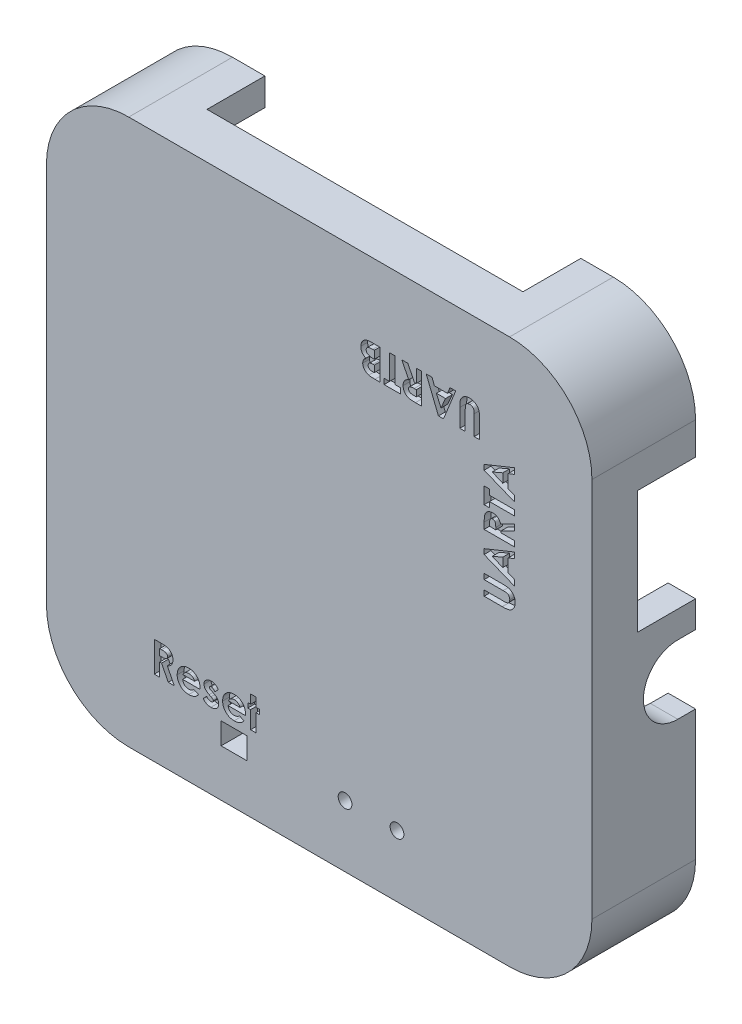
from build123d import *

# Parameters (mm, degrees)
BOSS_EXTRUDE1_DEPTH = 3.175
BOSS_EXTRUDE2_DEPTH = 8.8
CUT_EXTRUDE1_REACH  = 65.033
SKETCH3_W           = 6.6875
SKETCH3_H           = 14.175
SKETCH5_W           = 36.506
SKETCH5_H           = 6.6875
CUT_EXTRUDE2_DEPTH  = 3.175
SKETCH6_W           = 6.604
SKETCH6_H           = 12.954
CUT_EXTRUDE3_DEPTH  = 3.175
SKETCH7_R           = 0.79375
SKETCH7_W           = 3
SKETCH7_H           = 2.5
CUT_EXTRUDE4_DEPTH  = 3.175
CUT_EXTRUDE5_DEPTH  = 0.79375


with BuildPart() as part:
    # Sketch1 → Boss-Extrude1 (new body)
    with BuildSketch(Plane.XY):
        with BuildLine():
            Line((22, 31.5165), (-22, 31.5165))
            ThreePointArc((-22, 31.5165), (-28.729181683, 28.729181683), (-31.5165, 22))
            Line((-31.5165, 22), (-31.5165, -22))
            ThreePointArc((-31.5165, -22), (-28.729181683, -28.729181683), (-22, -31.5165))
            Line((-22, -31.5165), (22, -31.5165))
            ThreePointArc((22, -31.5165), (28.729181683, -28.729181683), (31.5165, -22))
            Line((31.5165, -22), (31.5165, 22))
            ThreePointArc((31.5165, 22), (28.729181683, 28.729181683), (22, 31.5165))
        make_face()
    extrude(amount=BOSS_EXTRUDE1_DEPTH)

    # Sketch1_3 → Boss-Extrude2 (add)
    with BuildSketch(Plane.XY):
        with BuildLine():
            Line((22, 31.5165), (-22, 31.5165))
            ThreePointArc((-22, 31.5165), (-28.729181683, 28.729181683), (-31.5165, 22))
            Line((-31.5165, 22), (-31.5165, -22))
            ThreePointArc((-31.5165, -22), (-28.729181683, -28.729181683), (-22, -31.5165))
            Line((-22, -31.5165), (22, -31.5165))
            ThreePointArc((22, -31.5165), (28.729181683, -28.729181683), (31.5165, -22))
            Line((31.5165, -22), (31.5165, 22))
            ThreePointArc((31.5165, 22), (28.729181683, 28.729181683), (22, 31.5165))
        make_face()
        with BuildLine():
            Line((-28.3415, 22), (-28.3415, -22))
            ThreePointArc((-28.3415, -22), (-26.484117653, -26.484117653), (-22, -28.3415))
            Line((-22, -28.3415), (22, -28.3415))
            ThreePointArc((22, -28.3415), (26.484117653, -26.484117653), (28.3415, -22))
            Line((28.3415, -22), (28.3415, 22))
            ThreePointArc((28.3415, 22), (26.484117653, 26.484117653), (22, 28.3415))
            Line((22, 28.3415), (-22, 28.3415))
            ThreePointArc((-22, 28.3415), (-26.484117653, 26.484117653), (-28.3415, 22))
        make_face(mode=Mode.SUBTRACT)
    extrude(amount=-BOSS_EXTRUDE2_DEPTH)

    # Sketch3 → Cut-Extrude1 (cut, up to next)
    with BuildSketch(Plane(origin=(31.5165, 0, 0), x_dir=(0, 0, -1), z_dir=(1, 0, 0)), mode=Mode.PRIVATE) as cut_extrude1_sk1:
        with BuildLine():
            Line((6.745, -6.94475), (8.8, -6.94475))
            Line((8.8, -6.94475), (8.8, -6.371283723))
            Line((8.8, -6.371283723), (8.8, 0.419283723))
            Line((8.8, 0.419283723), (8.8, 0.99275))
            Line((8.8, 0.99275), (6.745, 0.99275))
            ThreePointArc((6.745, 0.99275), (2.77625, -2.976), (6.745, -6.94475))
        make_face()
    cut_extrude1_tool1 = extrude(cut_extrude1_sk1.sketch, amount=-CUT_EXTRUDE1_REACH, mode=Mode.PRIVATE) & part.part
    add(cut_extrude1_tool1.solids().sort_by_distance((31.5165, -2.976, -6.13812))[0], mode=Mode.SUBTRACT)
    # Sketch3 → Cut-Extrude1 (cut, up to next)
    with BuildSketch(Plane(origin=(31.5165, 0, 0), x_dir=(0, 0, -1), z_dir=(1, 0, 0)), mode=Mode.PRIVATE) as cut_extrude1_sk2:
        with Locations((5.45625, 11.17)):
            Rectangle(SKETCH3_W, SKETCH3_H)
    cut_extrude1_tool2 = extrude(cut_extrude1_sk2.sketch, amount=-CUT_EXTRUDE1_REACH, mode=Mode.PRIVATE) & part.part
    add(cut_extrude1_tool2.solids().sort_by_distance((31.5165, 11.17, -5.45625))[0], mode=Mode.SUBTRACT)

    # Sketch5 → Cut-Extrude2 (cut)
    with BuildSketch(Plane(origin=(0, 31.5165, 0), x_dir=(1, 0, 0), z_dir=(0, 1, 0))):
        with Locations((0.0045, 5.45625)):
            Rectangle(SKETCH5_W, SKETCH5_H)
    extrude(amount=-CUT_EXTRUDE2_DEPTH, mode=Mode.SUBTRACT)

    # Sketch6 → Cut-Extrude3 (cut)
    with BuildSketch(Plane.ZY.offset(31.5165)):
        with Locations((-5.498, -8.73)):
            Rectangle(SKETCH6_W, SKETCH6_H)
    extrude(amount=-CUT_EXTRUDE3_DEPTH, mode=Mode.SUBTRACT)

    # Sketch7 → Cut-Extrude4 (cut)
    with BuildSketch(Plane.XY.offset(3.175)):
        with Locations((2.99, -24.39)):
            Circle(SKETCH7_R)
        with Locations((8.99, -24.39)):
            Circle(SKETCH7_R)
        with Locations((-9.83, -24.82)):
            Rectangle(SKETCH7_W, SKETCH7_H)
    extrude(amount=-CUT_EXTRUDE4_DEPTH, mode=Mode.SUBTRACT)

    # Sketch8 → Cut-Extrude5 (cut)
    with BuildSketch(Plane.XY.offset(3.175)):
        with BuildLine():
            Line((-19.05449378, -19.261955354), (-18.322522626, -19.261955354))
            add(Edge.make_bspline(
                [(-18.322522626, -19.261955354), (-18.274139555, -19.262127086), (-18.181085282, -19.262457375), (-18.046906103, -19.267668465), (-17.923644074, -19.274920124), (-17.811116694, -19.285986348), (-17.709372106, -19.300658824), (-17.618308337, -19.317955244), (-17.537928049, -19.337668224), (-17.467553345, -19.362232152), (-17.404043654, -19.38993989), (-17.344843793, -19.42177659), (-17.288647724, -19.457387739), (-17.235831058, -19.497710363), (-17.185934805, -19.542019068), (-17.138864833, -19.590358455), (-17.095286284, -19.643138422), (-17.055468999, -19.700025467), (-17.019178749, -19.759869333), (-16.987105779, -19.822752188), (-16.961023986, -19.888717761), (-16.937977926, -19.956812708), (-16.921378596, -20.028010459), (-16.909834005, -20.101617893), (-16.901381507, -20.177894114), (-16.900895529, -20.229712792), (-16.900647626, -20.256146059)],
                knots=[0, 0, 0, 0, 0.000145139, 0.000279143, 0.000402781, 0.00051552, 0.000618244, 0.00071106, 0.000793533, 0.000866261, 0.000934389, 0.001001202, 0.00106772, 0.001133767, 0.001200318, 0.00126775, 0.001335975, 0.001405418, 0.00147588, 0.001545802, 0.001616889, 0.001688503, 0.001761288, 0.001835865, 0.001911978, 0.001991232, 0.001991232, 0.001991232, 0.001991232], degree=3))
            add(Edge.make_bspline(
                [(-16.900647626, -20.256146059), (-16.901291588, -20.283736317), (-16.902554281, -20.337835786), (-16.909355829, -20.417303493), (-16.921786923, -20.493332636), (-16.940615624, -20.565700612), (-16.962256769, -20.635308125), (-16.991033942, -20.700870871), (-17.023511825, -20.763342367), (-17.062084859, -20.82183893), (-17.104416878, -20.877659884), (-17.153648126, -20.928666523), (-17.206589175, -20.977600259), (-17.266216032, -21.02139605), (-17.329900291, -21.063015209), (-17.398907292, -21.10073325), (-17.47278667, -21.135498319), (-17.524727531, -21.154885723), (-17.551288652, -21.164799905)],
                knots=[0, 0, 0, 0, 8.278e-05, 0.000162316, 0.000239082, 0.000313563, 0.00038651, 0.000457489, 0.000528056, 0.000597481, 0.00066746, 0.000737887, 0.000809857, 0.000883475, 0.000959513, 0.001037964, 0.001119203, 0.001204224, 0.001204224, 0.001204224, 0.001204224], degree=3))
            Line((-17.551288652, -21.164799905), (-16.743596344, -22.761955354))
            Line((-16.743596344, -22.761955354), (-17.441913652, -22.761955354))
            Line((-17.441913652, -22.761955354), (-18.213147626, -21.236314328))
            Line((-18.213147626, -21.236314328), (-18.426288652, -21.236314328))
            Line((-18.426288652, -21.236314328), (-18.426288652, -22.761955354))
            Line((-18.426288652, -22.761955354), (-19.05449378, -22.761955354))
            Line((-19.05449378, -22.761955354), (-19.05449378, -19.261955354))
        make_face()
        with BuildLine():
            Line((-18.426288652, -20.6081092), (-18.181597145, -20.6081092))
            add(Edge.make_bspline(
                [(-18.181597145, -20.6081092), (-18.151681574, -20.607772271), (-18.094399685, -20.607127123), (-18.012020804, -20.604134664), (-17.937201134, -20.596924314), (-17.869619373, -20.587814307), (-17.808935457, -20.577295488), (-17.755690665, -20.562221382), (-17.709064576, -20.546069095), (-17.66960971, -20.525995993), (-17.635900379, -20.503168522), (-17.606794529, -20.477235948), (-17.582719818, -20.447222296), (-17.562905103, -20.413943206), (-17.547491409, -20.377104335), (-17.536240593, -20.337110089), (-17.529953051, -20.293504882), (-17.529229648, -20.263411352), (-17.528852754, -20.247732597)],
                knots=[0, 0, 0, 0, 8.9755e-05, 0.000171861, 0.000247208, 0.00031513, 0.000376461, 0.000431743, 0.000480981, 0.000524253, 0.000564118, 0.000602839, 0.000640725, 0.000679082, 0.000718669, 0.000760178, 0.000803409, 0.000850432, 0.000850432, 0.000850432, 0.000850432], degree=3))
            add(Edge.make_bspline(
                [(-17.528852754, -20.247732597), (-17.529565306, -20.229183486), (-17.530964982, -20.192747195), (-17.54485412, -20.140291711), (-17.566962627, -20.091740572), (-17.597267334, -20.047313144), (-17.635432173, -20.008364993), (-17.679229337, -19.974031888), (-17.729604074, -19.946883838), (-17.77624729, -19.928977273), (-17.818681714, -19.91826359), (-17.856977442, -19.910279849), (-17.901324127, -19.904621542), (-17.951755247, -19.898619901), (-18.008142251, -19.89472814), (-18.070792482, -19.89188793), (-18.13952601, -19.890725861), (-18.187439807, -19.890354368), (-18.212446504, -19.890160482)],
                knots=[0, 0, 0, 0, 5.5548e-05, 0.000109114, 0.000161511, 0.00021499, 0.000269533, 0.000324507, 0.000381303, 0.00044055, 0.000473881, 0.00051252, 0.000557833, 0.000607927, 0.000664874, 0.000727337, 0.000796061, 0.000871084, 0.000871084, 0.000871084, 0.000871084], degree=3))
            Line((-18.212446504, -19.890160482), (-18.426288652, -19.890160482))
            Line((-18.426288652, -19.890160482), (-18.426288652, -20.6081092))
        make_face(mode=Mode.SUBTRACT)
        with BuildLine():
            Line((-13.76172535, -21.640160482), (-15.778852754, -21.640160482))
            add(Edge.make_bspline(
                [(-15.778852754, -21.640160482), (-15.774739994, -21.663598358), (-15.766658097, -21.709655634), (-15.749107968, -21.776557823), (-15.726711373, -21.839605317), (-15.699870463, -21.898882395), (-15.669037778, -21.954702431), (-15.633074004, -22.006803608), (-15.592435311, -22.055139906), (-15.547356659, -22.09950125), (-15.498589429, -22.139249977), (-15.446370124, -22.174072374), (-15.390644855, -22.202624609), (-15.332052493, -22.226691181), (-15.270155218, -22.245754343), (-15.204861933, -22.258901844), (-15.136345719, -22.266668121), (-15.089670381, -22.267791424), (-15.065811889, -22.26836561)],
                knots=[0, 0, 0, 0, 7.1366e-05, 0.000140241, 0.000207212, 0.000271852, 0.000335252, 0.000398263, 0.000461462, 0.000524426, 0.000587718, 0.000649944, 0.000712348, 0.000775234, 0.000839772, 0.000906323, 0.000974768, 0.001046337, 0.001046337, 0.001046337, 0.001046337], degree=3))
            add(Edge.make_bspline(
                [(-15.065811889, -22.26836561), (-15.037013068, -22.267605293), (-14.98029971, -22.266108006), (-14.897214218, -22.25282929), (-14.816858445, -22.232772374), (-14.739992838, -22.202946055), (-14.665727031, -22.165817532), (-14.595283668, -22.11955996), (-14.527443428, -22.065525138), (-14.486052886, -22.023875118), (-14.464950511, -22.00264045)],
                knots=[0, 0, 0, 0, 8.6341e-05, 0.00017003, 0.000251824, 0.000334378, 0.000416843, 0.000500464, 0.000586748, 0.000676494, 0.000676494, 0.000676494, 0.000676494], degree=3))
            Line((-14.464950511, -22.00264045), (-13.939109164, -22.252940931))
            add(Edge.make_bspline(
                [(-13.939109164, -22.252940931), (-13.955664972, -22.275818516), (-13.988469697, -22.321149611), (-14.042022309, -22.384942168), (-14.097907869, -22.444463212), (-14.156168058, -22.499321264), (-14.216876762, -22.54936), (-14.279865107, -22.595188981), (-14.34605364, -22.635577719), (-14.414118934, -22.672480196), (-14.485468023, -22.704116519), (-14.559903455, -22.731094858), (-14.637109953, -22.755483047), (-14.718062468, -22.77406551), (-14.802086909, -22.788775237), (-14.88938428, -22.799221092), (-14.979943074, -22.805672996), (-15.041495359, -22.806437861), (-15.072823107, -22.806827149)],
                knots=[0, 0, 0, 0, 8.4697e-05, 0.000167823, 0.000249662, 0.00032952, 0.00040771, 0.000485547, 0.000562988, 0.000640153, 0.000717677, 0.000796866, 0.00087759, 0.000960411, 0.001045824, 0.001133397, 0.001224062, 0.001318036, 0.001318036, 0.001318036, 0.001318036], degree=3))
            add(Edge.make_bspline(
                [(-15.072823107, -22.806827149), (-15.121020332, -22.805844552), (-15.215411819, -22.803920194), (-15.353476432, -22.786059393), (-15.484599521, -22.756444261), (-15.609151332, -22.716187037), (-15.726593468, -22.66303489), (-15.836984052, -22.598025405), (-15.941426044, -22.522404943), (-16.036728158, -22.434586434), (-16.123551196, -22.339001207), (-16.199811154, -22.236349201), (-16.263624401, -22.127347606), (-16.316029123, -22.012717817), (-16.356759893, -21.892166428), (-16.386124416, -21.765640831), (-16.40412522, -21.633201459), (-16.406069396, -21.542995463), (-16.407057882, -21.497131636)],
                knots=[0, 0, 0, 0, 0.00014454, 0.000283073, 0.000416765, 0.000547357, 0.00067507, 0.000802653, 0.00093111, 0.001061137, 0.001190693, 0.00131802, 0.001444038, 0.001568909, 0.001695509, 0.001825101, 0.001958073, 0.002095607, 0.002095607, 0.002095607, 0.002095607], degree=3))
            add(Edge.make_bspline(
                [(-16.407057882, -21.497131636), (-16.406059668, -21.45010235), (-16.404095725, -21.357574343), (-16.386279403, -21.222076885), (-16.35667871, -21.092793983), (-16.315828794, -20.969547601), (-16.264219058, -20.851952278), (-16.199593897, -20.741036831), (-16.12358904, -20.636415113), (-16.03707878, -20.538576555), (-15.941372937, -20.450266567), (-15.839676437, -20.37156472), (-15.730846614, -20.305985118), (-15.616114429, -20.252996839), (-15.49621375, -20.2099452), (-15.369758693, -20.18129793), (-15.237711387, -20.162063003), (-15.147446756, -20.160291587), (-15.1015691, -20.159391251)],
                knots=[0, 0, 0, 0, 0.000141037, 0.000277484, 0.000409125, 0.000538385, 0.000666452, 0.000793682, 0.000922706, 0.001053829, 0.001184805, 0.001312836, 0.00143897, 0.001565065, 0.001691461, 0.001820371, 0.001953436, 0.00209097, 0.00209097, 0.00209097, 0.00209097], degree=3))
            add(Edge.make_bspline(
                [(-15.1015691, -20.159391251), (-15.053140978, -20.160389092), (-14.958057351, -20.162348249), (-14.81903116, -20.180064024), (-14.687037429, -20.209859746), (-14.561513792, -20.249768873), (-14.444063236, -20.304263699), (-14.332105016, -20.367673404), (-14.228324527, -20.444928459), (-14.131615577, -20.532317213), (-14.044315985, -20.629272007), (-13.968006469, -20.734594608), (-13.903076462, -20.847257131), (-13.850450048, -20.967716444), (-13.809761101, -21.095610918), (-13.780369396, -21.230774456), (-13.762505895, -21.373721156), (-13.760597895, -21.471604954), (-13.759621985, -21.521670899)],
                knots=[0, 0, 0, 0, 0.000145241, 0.000285165, 0.000419541, 0.000550799, 0.000679441, 0.000807278, 0.000936149, 0.001066695, 0.001197762, 0.001326785, 0.001456187, 0.001587104, 0.001720363, 0.001858162, 0.002001564, 0.002151709, 0.002151709, 0.002151709, 0.002151709], degree=3))
            Line((-13.759621985, -21.521670899), (-13.76172535, -21.640160482))
        make_face()
        with BuildLine():
            add(Edge.make_bspline(
                [(-14.387827113, -21.146570738), (-14.399681728, -21.114579935), (-14.423251791, -21.050973883), (-14.476495582, -20.963213052), (-14.547148388, -20.887208608), (-14.629322671, -20.819921271), (-14.723211935, -20.765306665), (-14.825857564, -20.725763917), (-14.935962138, -20.702053589), (-15.011708152, -20.699272784), (-15.050387209, -20.69785279)],
                knots=[0, 0, 0, 0, 0.000102205, 0.000203211, 0.000305459, 0.000412113, 0.00052082, 0.000629801, 0.000740911, 0.000856853, 0.000856853, 0.000856853, 0.000856853], degree=3))
            add(Edge.make_bspline(
                [(-15.050387209, -20.69785279), (-15.092631038, -20.699216867), (-15.175208926, -20.701883355), (-15.294321908, -20.730242428), (-15.406678203, -20.772567497), (-15.472917107, -20.816205542), (-15.506116376, -20.838077149)],
                knots=[0, 0, 0, 0, 0.000126482, 0.000247246, 0.000365595, 0.000484515, 0.000484515, 0.000484515, 0.000484515], degree=3))
            add(Edge.make_bspline(
                [(-15.506116376, -20.838077149), (-15.52683024, -20.854735043), (-15.570991141, -20.890248822), (-15.628343029, -20.96109544), (-15.684835117, -21.046874791), (-15.716953983, -21.112030267), (-15.733980959, -21.146570738)],
                knots=[0, 0, 0, 0, 7.9546e-05, 0.000169587, 0.000271874, 0.000387276, 0.000387276, 0.000387276, 0.000387276], degree=3))
            Line((-15.733980959, -21.146570738), (-14.387827113, -21.146570738))
        make_face(mode=Mode.SUBTRACT)
        with BuildLine():
            Line((-11.650647626, -20.598994616), (-12.03486237, -21.011955354))
            add(Edge.make_bspline(
                [(-12.03486237, -21.011955354), (-12.054048052, -20.990725355), (-12.090742996, -20.950120411), (-12.146919408, -20.894766796), (-12.202259244, -20.848673587), (-12.255731249, -20.80995337), (-12.308427515, -20.780259593), (-12.359910015, -20.758895585), (-12.410203451, -20.745333395), (-12.443540067, -20.743577821), (-12.459742177, -20.742724584)],
                knots=[0, 0, 0, 0, 8.5838e-05, 0.000164176, 0.00023635, 0.000301717, 0.000361984, 0.00041732, 0.000468674, 0.000517234, 0.000517234, 0.000517234, 0.000517234], degree=3))
            add(Edge.make_bspline(
                [(-12.459742177, -20.742724584), (-12.476137085, -20.743224245), (-12.507528234, -20.74418094), (-12.551828179, -20.752386981), (-12.590748644, -20.76659315), (-12.62368225, -20.785957482), (-12.650141693, -20.80981235), (-12.668667182, -20.837101757), (-12.681107219, -20.866976937), (-12.682159566, -20.888198432), (-12.682698908, -20.899074745)],
                knots=[0, 0, 0, 0, 4.9159e-05, 9.4123e-05, 0.000134497, 0.000172855, 0.000208085, 0.000240368, 0.000271225, 0.000303666, 0.000303666, 0.000303666, 0.000303666], degree=3))
            add(Edge.make_bspline(
                [(-12.682698908, -20.899074745), (-12.680871567, -20.915557059), (-12.677080046, -20.949755946), (-12.651037557, -20.989421553), (-12.616581464, -21.018682059), (-12.576863551, -21.04591064), (-12.523075215, -21.076355109), (-12.482270018, -21.097201327), (-12.459742177, -21.108710161)],
                knots=[0, 0, 0, 0, 4.9229e-05, 0.000102143, 0.000136904, 0.00018475, 0.000246321, 0.000322211, 0.000322211, 0.000322211, 0.000322211], degree=3))
            Line((-12.459742177, -21.108710161), (-12.232578716, -21.223694136))
            add(Edge.make_bspline(
                [(-12.232578716, -21.223694136), (-12.20367918, -21.238368381), (-12.147608652, -21.266839174), (-12.068778742, -21.312780621), (-11.995970181, -21.357310371), (-11.930643487, -21.40294735), (-11.872398818, -21.448898691), (-11.821649883, -21.495618792), (-11.777165766, -21.541626538), (-11.727559731, -21.603310348), (-11.677938807, -21.685468163), (-11.636570369, -21.792310573), (-11.610190218, -21.906715302), (-11.607271559, -21.985899178), (-11.605775831, -22.026478591)],
                knots=[0, 0, 0, 0, 9.7214e-05, 0.000188612, 0.000273633, 0.000353185, 0.000427534, 0.000496015, 0.000559986, 0.000619333, 0.000733202, 0.000846214, 0.000961882, 0.001083467, 0.001083467, 0.001083467, 0.001083467], degree=3))
            add(Edge.make_bspline(
                [(-11.605775831, -22.026478591), (-11.606677016, -22.053855188), (-11.608440875, -22.107438455), (-11.61959162, -22.186307915), (-11.639621245, -22.261301094), (-11.6659802, -22.333586986), (-11.701484924, -22.401858442), (-11.744589398, -22.466446418), (-11.794612987, -22.528198919), (-11.852878137, -22.585003513), (-11.916706633, -22.637944773), (-11.987662779, -22.682472174), (-12.062609201, -22.721621994), (-12.143525866, -22.752194518), (-12.229277412, -22.776980712), (-12.320598906, -22.794156923), (-12.417180477, -22.804966353), (-12.483316618, -22.806196351), (-12.517234164, -22.806827149)],
                knots=[0, 0, 0, 0, 8.2139e-05, 0.000160768, 0.000238314, 0.00031463, 0.000391142, 0.000468536, 0.000547268, 0.000629071, 0.000712292, 0.000795534, 0.000879885, 0.000965559, 0.001054547, 0.001147363, 0.00124399, 0.001345713, 0.001345713, 0.001345713, 0.001345713], degree=3))
            add(Edge.make_bspline(
                [(-12.517234164, -22.806827149), (-12.562172, -22.805396128), (-12.650381016, -22.802587161), (-12.779203897, -22.783020298), (-12.900846897, -22.749149728), (-13.015410094, -22.701701392), (-13.123595172, -22.641239205), (-13.223857126, -22.566218866), (-13.317934089, -22.478594972), (-13.372669043, -22.411391525), (-13.400647626, -22.377039488)],
                knots=[0, 0, 0, 0, 0.000134798, 0.000264596, 0.000389797, 0.00051271, 0.000635766, 0.000760568, 0.000887546, 0.001020325, 0.001020325, 0.001020325, 0.001020325], degree=3))
            Line((-13.400647626, -22.377039488), (-13.019938491, -21.954263046))
            add(Edge.make_bspline(
                [(-13.019938491, -21.954263046), (-13.001389057, -21.973827929), (-12.964562362, -22.012670622), (-12.902487437, -22.063889964), (-12.836807769, -22.110572625), (-12.766792188, -22.149770829), (-12.69676246, -22.181421616), (-12.629574713, -22.205164133), (-12.566495176, -22.220084702), (-12.525482487, -22.222396529), (-12.506016216, -22.223493815)],
                knots=[0, 0, 0, 0, 8.0812e-05, 0.000160438, 0.000240966, 0.000322278, 0.000400728, 0.000471239, 0.000535879, 0.000594279, 0.000594279, 0.000594279, 0.000594279], degree=3))
            add(Edge.make_bspline(
                [(-12.506016216, -22.223493815), (-12.486560481, -22.222930364), (-12.449161191, -22.221847256), (-12.396007115, -22.210580802), (-12.348894208, -22.191640228), (-12.308940709, -22.165378642), (-12.275708457, -22.135234352), (-12.252292707, -22.100975189), (-12.236808973, -22.064647437), (-12.234927107, -22.039248456), (-12.233980959, -22.026478591)],
                knots=[0, 0, 0, 0, 5.8299e-05, 0.000112066, 0.000162062, 0.000209708, 0.000254847, 0.000295687, 0.000333444, 0.000371621, 0.000371621, 0.000371621, 0.000371621], degree=3))
            add(Edge.make_bspline(
                [(-12.233980959, -22.026478591), (-12.234825203, -22.014453074), (-12.236558599, -21.989762371), (-12.25028195, -21.953317126), (-12.271827881, -21.917230486), (-12.301710912, -21.881400706), (-12.340328675, -21.846118502), (-12.387542966, -21.811666473), (-12.44226455, -21.776206561), (-12.482685026, -21.755041741), (-12.50391285, -21.743926508)],
                knots=[0, 0, 0, 0, 3.6004e-05, 7.3923e-05, 0.000115408, 0.000161729, 0.000213327, 0.000271941, 0.0003369, 0.000408747, 0.000408747, 0.000408747, 0.000408747], degree=3))
            Line((-12.50391285, -21.743926508), (-12.712146023, -21.638758238))
            add(Edge.make_bspline(
                [(-12.712146023, -21.638758238), (-12.75938162, -21.613428622), (-12.850056254, -21.564805255), (-12.972614464, -21.481426515), (-13.076342296, -21.392668186), (-13.161324278, -21.29900711), (-13.229038091, -21.200706121), (-13.276273018, -21.096513655), (-13.305988101, -20.987417481), (-13.309257236, -20.912816334), (-13.310904036, -20.875236604)],
                knots=[0, 0, 0, 0, 0.000160714, 0.000308512, 0.000443724, 0.000569319, 0.000686968, 0.000800233, 0.00091111, 0.001023659, 0.001023659, 0.001023659, 0.001023659], degree=3))
            add(Edge.make_bspline(
                [(-13.310904036, -20.875236604), (-13.31033294, -20.850880955), (-13.309211784, -20.803066858), (-13.29727641, -20.732848545), (-13.279244621, -20.665350894), (-13.253799824, -20.600466715), (-13.221205484, -20.538131625), (-13.181271763, -20.478622261), (-13.133511472, -20.422046813), (-13.07945362, -20.368587522), (-13.019474737, -20.319899845), (-12.955288511, -20.276751177), (-12.887084792, -20.239996536), (-12.814303842, -20.210693121), (-12.737870747, -20.187369427), (-12.657280965, -20.171515643), (-12.572878331, -20.161432581), (-12.51516039, -20.160081336), (-12.485683684, -20.159391251)],
                knots=[0, 0, 0, 0, 7.3001e-05, 0.000143313, 0.000213045, 0.000282311, 0.000351931, 0.000423685, 0.000496847, 0.000573693, 0.000651439, 0.000728249, 0.000805414, 0.000883402, 0.00096325, 0.001044789, 0.001129494, 0.001217905, 0.001217905, 0.001217905, 0.001217905], degree=3))
            add(Edge.make_bspline(
                [(-12.485683684, -20.159391251), (-12.444931946, -20.160732966), (-12.364046935, -20.163396035), (-12.244757453, -20.184945599), (-12.129536186, -20.221165442), (-12.018706155, -20.271070328), (-11.913692979, -20.333786588), (-11.816805948, -20.409945309), (-11.727389366, -20.497671118), (-11.676482226, -20.564884729), (-11.650647626, -20.598994616)],
                knots=[0, 0, 0, 0, 0.000122196, 0.000242538, 0.000362285, 0.000483733, 0.000606379, 0.000728257, 0.000852696, 0.000980917, 0.000980917, 0.000980917, 0.000980917], degree=3))
        make_face()
        with BuildLine():
            Line((-8.51172535, -21.640160482), (-10.528852754, -21.640160482))
            add(Edge.make_bspline(
                [(-10.528852754, -21.640160482), (-10.524739994, -21.663598358), (-10.516658097, -21.709655634), (-10.499107968, -21.776557823), (-10.476711373, -21.839605317), (-10.449870463, -21.898882395), (-10.419037778, -21.954702431), (-10.383074004, -22.006803608), (-10.342435311, -22.055139906), (-10.297356659, -22.09950125), (-10.248589429, -22.139249977), (-10.196370124, -22.174072374), (-10.140644855, -22.202624609), (-10.082052493, -22.226691181), (-10.020155218, -22.245754343), (-9.954861933, -22.258901844), (-9.886345719, -22.266668121), (-9.839670381, -22.267791424), (-9.815811889, -22.26836561)],
                knots=[0, 0, 0, 0, 7.1366e-05, 0.000140241, 0.000207212, 0.000271852, 0.000335252, 0.000398263, 0.000461462, 0.000524426, 0.000587718, 0.000649944, 0.000712348, 0.000775234, 0.000839772, 0.000906323, 0.000974768, 0.001046337, 0.001046337, 0.001046337, 0.001046337], degree=3))
            add(Edge.make_bspline(
                [(-9.815811889, -22.26836561), (-9.787013068, -22.267605293), (-9.73029971, -22.266108006), (-9.647214218, -22.25282929), (-9.566858445, -22.232772374), (-9.489992838, -22.202946055), (-9.415727031, -22.165817532), (-9.345283668, -22.11955996), (-9.277443428, -22.065525138), (-9.236052886, -22.023875118), (-9.214950511, -22.00264045)],
                knots=[0, 0, 0, 0, 8.6341e-05, 0.00017003, 0.000251824, 0.000334378, 0.000416843, 0.000500464, 0.000586748, 0.000676494, 0.000676494, 0.000676494, 0.000676494], degree=3))
            Line((-9.214950511, -22.00264045), (-8.689109164, -22.252940931))
            add(Edge.make_bspline(
                [(-8.689109164, -22.252940931), (-8.705664972, -22.275818516), (-8.738469697, -22.321149611), (-8.792022309, -22.384942168), (-8.847907869, -22.444463212), (-8.906168058, -22.499321264), (-8.966876762, -22.54936), (-9.029865107, -22.595188981), (-9.09605364, -22.635577719), (-9.164118934, -22.672480196), (-9.235468023, -22.704116519), (-9.309903455, -22.731094858), (-9.387109953, -22.755483047), (-9.468062468, -22.77406551), (-9.552086909, -22.788775237), (-9.63938428, -22.799221092), (-9.729943074, -22.805672996), (-9.791495359, -22.806437861), (-9.822823107, -22.806827149)],
                knots=[0, 0, 0, 0, 8.4697e-05, 0.000167823, 0.000249662, 0.00032952, 0.00040771, 0.000485547, 0.000562988, 0.000640153, 0.000717677, 0.000796866, 0.00087759, 0.000960411, 0.001045824, 0.001133397, 0.001224062, 0.001318036, 0.001318036, 0.001318036, 0.001318036], degree=3))
            add(Edge.make_bspline(
                [(-9.822823107, -22.806827149), (-9.871020332, -22.805844552), (-9.965411819, -22.803920194), (-10.103476432, -22.786059393), (-10.234599521, -22.756444261), (-10.359151332, -22.716187037), (-10.476593468, -22.66303489), (-10.586984052, -22.598025405), (-10.691426044, -22.522404943), (-10.786728158, -22.434586434), (-10.873551196, -22.339001207), (-10.949811154, -22.236349201), (-11.013624401, -22.127347606), (-11.066029123, -22.012717817), (-11.106759893, -21.892166428), (-11.136124416, -21.765640831), (-11.15412522, -21.633201459), (-11.156069396, -21.542995463), (-11.157057882, -21.497131636)],
                knots=[0, 0, 0, 0, 0.00014454, 0.000283073, 0.000416765, 0.000547357, 0.00067507, 0.000802653, 0.00093111, 0.001061137, 0.001190693, 0.00131802, 0.001444038, 0.001568909, 0.001695509, 0.001825101, 0.001958073, 0.002095607, 0.002095607, 0.002095607, 0.002095607], degree=3))
            add(Edge.make_bspline(
                [(-11.157057882, -21.497131636), (-11.156059668, -21.45010235), (-11.154095725, -21.357574343), (-11.136279403, -21.222076885), (-11.10667871, -21.092793983), (-11.065828794, -20.969547601), (-11.014219058, -20.851952278), (-10.949593897, -20.741036831), (-10.87358904, -20.636415113), (-10.78707878, -20.538576555), (-10.691372937, -20.450266567), (-10.589676437, -20.37156472), (-10.480846614, -20.305985118), (-10.366114429, -20.252996839), (-10.24621375, -20.2099452), (-10.119758693, -20.18129793), (-9.987711387, -20.162063003), (-9.897446756, -20.160291587), (-9.8515691, -20.159391251)],
                knots=[0, 0, 0, 0, 0.000141037, 0.000277484, 0.000409125, 0.000538385, 0.000666452, 0.000793682, 0.000922706, 0.001053829, 0.001184805, 0.001312836, 0.00143897, 0.001565065, 0.001691461, 0.001820371, 0.001953436, 0.00209097, 0.00209097, 0.00209097, 0.00209097], degree=3))
            add(Edge.make_bspline(
                [(-9.8515691, -20.159391251), (-9.803140978, -20.160389092), (-9.708057351, -20.162348249), (-9.56903116, -20.180064024), (-9.437037429, -20.209859746), (-9.311513792, -20.249768873), (-9.194063236, -20.304263699), (-9.082105016, -20.367673404), (-8.978324527, -20.444928459), (-8.881615577, -20.532317213), (-8.794315985, -20.629272007), (-8.718006469, -20.734594608), (-8.653076462, -20.847257131), (-8.600450048, -20.967716444), (-8.559761101, -21.095610918), (-8.530369396, -21.230774456), (-8.512505895, -21.373721156), (-8.510597895, -21.471604954), (-8.509621985, -21.521670899)],
                knots=[0, 0, 0, 0, 0.000145241, 0.000285165, 0.000419541, 0.000550799, 0.000679441, 0.000807278, 0.000936149, 0.001066695, 0.001197762, 0.001326785, 0.001456187, 0.001587104, 0.001720363, 0.001858162, 0.002001564, 0.002151709, 0.002151709, 0.002151709, 0.002151709], degree=3))
            Line((-8.509621985, -21.521670899), (-8.51172535, -21.640160482))
        make_face()
        with BuildLine():
            add(Edge.make_bspline(
                [(-9.137827113, -21.146570738), (-9.149681728, -21.114579935), (-9.173251791, -21.050973883), (-9.226495582, -20.963213052), (-9.297148388, -20.887208608), (-9.379322671, -20.819921271), (-9.473211935, -20.765306665), (-9.575857564, -20.725763917), (-9.685962138, -20.702053589), (-9.761708152, -20.699272784), (-9.800387209, -20.69785279)],
                knots=[0, 0, 0, 0, 0.000102205, 0.000203211, 0.000305459, 0.000412113, 0.00052082, 0.000629801, 0.000740911, 0.000856853, 0.000856853, 0.000856853, 0.000856853], degree=3))
            add(Edge.make_bspline(
                [(-9.800387209, -20.69785279), (-9.842631038, -20.699216867), (-9.925208926, -20.701883355), (-10.044321908, -20.730242428), (-10.156678203, -20.772567497), (-10.222917107, -20.816205542), (-10.256116376, -20.838077149)],
                knots=[0, 0, 0, 0, 0.000126482, 0.000247246, 0.000365595, 0.000484515, 0.000484515, 0.000484515, 0.000484515], degree=3))
            add(Edge.make_bspline(
                [(-10.256116376, -20.838077149), (-10.27683024, -20.854735043), (-10.320991141, -20.890248822), (-10.378343029, -20.96109544), (-10.434835117, -21.046874791), (-10.466953983, -21.112030267), (-10.483980959, -21.146570738)],
                knots=[0, 0, 0, 0, 7.9546e-05, 0.000169587, 0.000271874, 0.000387276, 0.000387276, 0.000387276, 0.000387276], degree=3))
            Line((-10.483980959, -21.146570738), (-9.137827113, -21.146570738))
        make_face(mode=Mode.SUBTRACT)
        Polygon((-7.926288652, -19.172211764), (-7.298083523, -19.172211764), (-7.298083523, -20.204263046), (-6.89423737, -20.204263046), (-6.89423737, -20.742724584), (-7.298083523, -20.742724584), (-7.298083523, -22.761955354), (-7.926288652, -22.761955354), (-7.926288652, -20.742724584), (-8.240391216, -20.742724584), (-8.240391216, -20.204263046), (-7.926288652, -20.204263046), align=None)
        with BuildLine():
            Line((19.058552866, 4.096717429), (19.058552866, 4.724922558))
            Line((19.058552866, 4.724922558), (21.335796456, 4.724922558))
            add(Edge.make_bspline(
                [(21.335796456, 4.724922558), (21.359405767, 4.724958105), (21.405006907, 4.725026766), (21.470432232, 4.728311139), (21.530794815, 4.731406619), (21.585605371, 4.736673481), (21.635034042, 4.744934926), (21.679262937, 4.752648147), (21.717897897, 4.763223115), (21.76190469, 4.779059179), (21.811341604, 4.803782852), (21.86345014, 4.842996784), (21.909831137, 4.889824859), (21.948774785, 4.944972075), (21.98171377, 5.006542025), (22.003500151, 5.07574808), (22.018277462, 5.150340452), (22.019475398, 5.202309013), (22.020091328, 5.229029128)],
                knots=[0, 0, 0, 0, 7.0817e-05, 0.000136782, 0.00019648, 0.000252152, 0.000301833, 0.000346798, 0.000386768, 0.00042181, 0.000487029, 0.000551673, 0.000616621, 0.000683943, 0.000753563, 0.000825177, 0.000900807, 0.000980846, 0.000980846, 0.000980846, 0.000980846], degree=3))
            add(Edge.make_bspline(
                [(22.020091328, 5.229029128), (22.019263878, 5.257385166), (22.017650491, 5.312674638), (22.001813353, 5.392199743), (21.976595206, 5.465880201), (21.940602483, 5.532155956), (21.897458894, 5.59096102), (21.848261693, 5.640738361), (21.792912708, 5.68002215), (21.741849177, 5.70562682), (21.694849338, 5.720000305), (21.652857823, 5.730782544), (21.603536221, 5.7386118), (21.547227098, 5.745941598), (21.483520181, 5.750097148), (21.412748489, 5.754829682), (21.334868962, 5.756526809), (21.280641113, 5.756820624), (21.252362962, 5.75697384)],
                knots=[0, 0, 0, 0, 8.4978e-05, 0.000165692, 0.000242191, 0.000317789, 0.000390988, 0.000460396, 0.00052674, 0.000593843, 0.00063065, 0.000674012, 0.000723806, 0.000780333, 0.000844323, 0.000915261, 0.000993114, 0.001077953, 0.001077953, 0.001077953, 0.001077953], degree=3))
            Line((21.252362962, 5.75697384), (19.058552866, 5.75697384))
            Line((19.058552866, 5.75697384), (19.058552866, 6.385178968))
            Line((19.058552866, 6.385178968), (21.146493571, 6.385178968))
            add(Edge.make_bspline(
                [(21.146493571, 6.385178968), (21.18879515, 6.38509173), (21.270136961, 6.384923981), (21.387030867, 6.382347853), (21.4937947, 6.376863742), (21.590459655, 6.372257722), (21.676895509, 6.363343495), (21.753471371, 6.354056964), (21.819915857, 6.342220473), (21.89555488, 6.32460852), (21.98265013, 6.294215283), (22.082938002, 6.245218447), (22.181120184, 6.183016145), (22.276145006, 6.10951165), (22.364335039, 6.026459962), (22.441974668, 5.936063536), (22.506576122, 5.838737046), (22.558809359, 5.73493005), (22.599028634, 5.623547128), (22.627456644, 5.504325583), (22.645546173, 5.376583629), (22.647361319, 5.288454458), (22.648296456, 5.243051564)],
                knots=[0, 0, 0, 0, 0.000126905, 0.000244026, 0.000350709, 0.000447627, 0.000534274, 0.000611324, 0.000678989, 0.000736639, 0.000844176, 0.000954866, 0.001070804, 0.001192252, 0.001314756, 0.001433618, 0.001548931, 0.001664318, 0.001781424, 0.001903351, 0.002031459, 0.002167592, 0.002167592, 0.002167592, 0.002167592], degree=3))
            add(Edge.make_bspline(
                [(22.648296456, 5.243051564), (22.647786814, 5.212881492), (22.646781302, 5.153356558), (22.637961612, 5.065807132), (22.62485782, 4.981202385), (22.606111454, 4.899497435), (22.580521358, 4.820974019), (22.550280104, 4.74512391), (22.515678368, 4.671672348), (22.473685209, 4.602914793), (22.429576225, 4.537162107), (22.381314182, 4.476620174), (22.331039285, 4.42035813), (22.277600777, 4.369029469), (22.221379329, 4.322586215), (22.162319908, 4.281064461), (22.100408749, 4.24454173), (22.034535069, 4.212094304), (21.961348883, 4.18432537), (21.878249461, 4.160903377), (21.784150706, 4.140542121), (21.678432716, 4.125128571), (21.56157684, 4.111543445), (21.433137129, 4.102740841), (21.293529177, 4.098197172), (21.196743881, 4.09722314), (21.146493571, 4.096717429)],
                knots=[0, 0, 0, 0, 9.0488e-05, 0.000178531, 0.000263714, 0.000347218, 0.000429701, 0.000511203, 0.000592109, 0.000672911, 0.000752642, 0.00082951, 0.000904971, 0.000978856, 0.00105157, 0.00112354, 0.001195205, 0.001267011, 0.001343575, 0.001429673, 0.001525798, 0.001632196, 0.001750039, 0.001878667, 0.002018277, 0.002169033, 0.002169033, 0.002169033, 0.002169033], degree=3))
            Line((21.146493571, 4.096717429), (19.058552866, 4.096717429))
        make_face()
        Polygon((19.058552866, 8.270495474), (19.058552866, 8.853127686), (22.558552866, 10.266589224), (22.558552866, 9.595615667), (21.840604148, 9.32358041), (21.840604148, 7.798640506), (22.558552866, 7.52660525), (22.558552866, 6.856332814), align=None)
        Polygon((19.99735495, 8.561461019), (21.21239902, 8.037021917), (21.21239902, 9.085900122), align=None, mode=Mode.SUBTRACT)
        with BuildLine():
            Line((19.058552866, 10.782614865), (19.058552866, 11.514586019))
            add(Edge.make_bspline(
                [(19.058552866, 11.514586019), (19.058722067, 11.562969448), (19.059047488, 11.65602441), (19.064292086, 11.790198848), (19.071431233, 11.913476797), (19.082861562, 12.025919636), (19.096337096, 12.127800482), (19.113902664, 12.218792816), (19.133552075, 12.299183229), (19.158135393, 12.369551606), (19.185821071, 12.433076563), (19.217726274, 12.492222889), (19.253162914, 12.548736992), (19.294425198, 12.600797628), (19.33783148, 12.651448482), (19.386309133, 12.698196055), (19.439016063, 12.741843534), (19.495941741, 12.78160295), (19.555883079, 12.818165345), (19.61905688, 12.849616348), (19.684949273, 12.876431512), (19.753235417, 12.898962921), (19.824596446, 12.9157624), (19.898218577, 12.927265736), (19.974490788, 12.935729491), (20.026310021, 12.936213911), (20.052743571, 12.936461019)],
                knots=[0, 0, 0, 0, 0.000145139, 0.000279143, 0.000402781, 0.00051552, 0.000618146, 0.000710961, 0.000793435, 0.000866163, 0.000934291, 0.001001103, 0.001067621, 0.001134095, 0.001200183, 0.001267615, 0.00133584, 0.001405283, 0.001475745, 0.001546294, 0.001616731, 0.001689011, 0.001761797, 0.001836373, 0.001912486, 0.001991741, 0.001991741, 0.001991741, 0.001991741], degree=3))
            add(Edge.make_bspline(
                [(20.052743571, 12.936461019), (20.080333215, 12.935814762), (20.134431478, 12.934547571), (20.213907857, 12.927778377), (20.290129658, 12.915193651), (20.362607734, 12.896753402), (20.432084388, 12.874681507), (20.497475267, 12.846096275), (20.559937128, 12.813590466), (20.618440656, 12.775028035), (20.674243112, 12.732680997), (20.725317771, 12.683499932), (20.774085778, 12.630263766), (20.818886411, 12.571352489), (20.859440779, 12.506942475), (20.897396142, 12.438244889), (20.932078348, 12.364310333), (20.95147732, 12.312377174), (20.961397418, 12.285819993)],
                knots=[0, 0, 0, 0, 8.278e-05, 0.000162316, 0.000239082, 0.000314243, 0.000386523, 0.000457503, 0.000528069, 0.000597494, 0.000667473, 0.0007379, 0.00080987, 0.000883911, 0.00095957, 0.001038021, 0.00111926, 0.001204281, 0.001204281, 0.001204281, 0.001204281], degree=3))
            Line((20.961397418, 12.285819993), (22.558552866, 13.093512301))
            Line((22.558552866, 13.093512301), (22.558552866, 12.395194993))
            Line((22.558552866, 12.395194993), (21.032911841, 11.623961019))
            Line((21.032911841, 11.623961019), (21.032911841, 11.410819993))
            Line((21.032911841, 11.410819993), (22.558552866, 11.410819993))
            Line((22.558552866, 11.410819993), (22.558552866, 10.782614865))
            Line((22.558552866, 10.782614865), (19.058552866, 10.782614865))
        make_face()
        with BuildLine():
            Line((20.404706712, 11.410819993), (20.404706712, 11.6555115))
            add(Edge.make_bspline(
                [(20.404706712, 11.6555115), (20.404369783, 11.685427071), (20.403724636, 11.74270896), (20.400732176, 11.825087841), (20.393521827, 11.899907511), (20.384411819, 11.967489272), (20.373893, 12.028173188), (20.358818894, 12.08141798), (20.342666608, 12.128044069), (20.322593506, 12.167498935), (20.299766035, 12.201208266), (20.273833461, 12.230314116), (20.243819808, 12.254388827), (20.210540719, 12.274203542), (20.173701848, 12.289617236), (20.133707601, 12.300868052), (20.090102395, 12.307155594), (20.060008864, 12.307878997), (20.04433011, 12.308255891)],
                knots=[0, 0, 0, 0, 8.9755e-05, 0.000171861, 0.000247208, 0.00031513, 0.000376461, 0.000431743, 0.000480981, 0.000524253, 0.000564118, 0.000602839, 0.000640725, 0.000679082, 0.000718669, 0.000760178, 0.000803409, 0.000850432, 0.000850432, 0.000850432, 0.000850432], degree=3))
            add(Edge.make_bspline(
                [(20.04433011, 12.308255891), (20.02577063, 12.307578181), (19.989540772, 12.306255228), (19.937235472, 12.291951179), (19.888474012, 12.270366457), (19.843918204, 12.239815339), (19.804974667, 12.201678022), (19.770571888, 12.157899897), (19.743671461, 12.107341297), (19.724781358, 12.060988026), (19.714177803, 12.018417213), (19.706215393, 11.980129718), (19.700298736, 11.935831522), (19.695509303, 11.885298155), (19.691234107, 11.828975981), (19.688513567, 11.766313218), (19.687315282, 11.697583483), (19.686949106, 11.649669129), (19.686757995, 11.624662141)],
                knots=[0, 0, 0, 0, 5.5548e-05, 0.000108435, 0.000161471, 0.000214949, 0.000269493, 0.000324467, 0.000381263, 0.000440763, 0.000474094, 0.000512732, 0.000558045, 0.000608066, 0.000665013, 0.000727476, 0.0007962, 0.000871223, 0.000871223, 0.000871223, 0.000871223], degree=3))
            Line((19.686757995, 11.624662141), (19.686757995, 11.410819993))
            Line((19.686757995, 11.410819993), (20.404706712, 11.410819993))
        make_face(mode=Mode.SUBTRACT)
        Polygon((19.058552866, 13.250563583), (19.058552866, 15.135178968), (19.686757995, 15.135178968), (19.686757995, 14.50697384), (22.558552866, 14.50697384), (22.558552866, 13.878768711), (19.686757995, 13.878768711), (19.686757995, 13.250563583), align=None)
        Polygon((19.058552866, 16.70639291), (19.058552866, 17.289025122), (22.558552866, 18.70248666), (22.558552866, 18.031513102), (21.840604148, 17.759477846), (21.840604148, 16.234537942), (22.558552866, 15.962502686), (22.558552866, 15.29223025), align=None)
        Polygon((19.99735495, 16.997358455), (21.21239902, 16.472919352), (21.21239902, 17.521797558), align=None, mode=Mode.SUBTRACT)
        with BuildLine():
            Line((18.536679502, 19.496300754), (17.908474374, 19.496300754))
            Line((17.908474374, 19.496300754), (17.908474374, 21.773544343))
            add(Edge.make_bspline(
                [(17.908474374, 21.773544343), (17.908438826, 21.797153654), (17.908370166, 21.842754795), (17.905085792, 21.908180119), (17.901990312, 21.968542703), (17.89672345, 22.023353259), (17.888462006, 22.07278193), (17.880748785, 22.117010825), (17.870173816, 22.155645785), (17.854337753, 22.199652577), (17.829614079, 22.249089491), (17.790400148, 22.301198027), (17.743572072, 22.347579024), (17.688424857, 22.386522672), (17.626854906, 22.419461658), (17.557648851, 22.441248038), (17.483056479, 22.456025349), (17.431087918, 22.457223285), (17.404367803, 22.457839215)],
                knots=[0, 0, 0, 0, 7.0817e-05, 0.000136782, 0.00019648, 0.000252152, 0.000301833, 0.000346798, 0.000386768, 0.00042181, 0.000487029, 0.000551673, 0.000616621, 0.000683943, 0.000753563, 0.000825177, 0.000900807, 0.000980846, 0.000980846, 0.000980846, 0.000980846], degree=3))
            add(Edge.make_bspline(
                [(17.404367803, 22.457839215), (17.376008414, 22.457020688), (17.320712408, 22.455424697), (17.241016309, 22.439420605), (17.166971907, 22.414530569), (17.100602232, 22.378281372), (17.04166784, 22.335490444), (16.99277309, 22.285526803), (16.952504919, 22.230943883), (16.927191614, 22.179553128), (16.912509473, 22.132702026), (16.902891511, 22.090481224), (16.894692183, 22.04130695), (16.887485318, 21.984967617), (16.883290342, 21.921270389), (16.878570153, 21.850495663), (16.876869289, 21.772617054), (16.876576022, 21.71838907), (16.876423092, 21.69011085)],
                knots=[0, 0, 0, 0, 8.4978e-05, 0.000165692, 0.000242854, 0.000318451, 0.00039165, 0.000460564, 0.000527318, 0.000594421, 0.000631228, 0.000674425, 0.00072422, 0.000780746, 0.000844737, 0.000915675, 0.000993528, 0.001078366, 0.001078366, 0.001078366, 0.001078366], degree=3))
            Line((16.876423092, 21.69011085), (16.876423092, 19.496300754))
            Line((16.876423092, 19.496300754), (16.248217964, 19.496300754))
            Line((16.248217964, 19.496300754), (16.248217964, 21.584241459))
            add(Edge.make_bspline(
                [(16.248217964, 21.584241459), (16.24829391, 21.62654382), (16.248439949, 21.707887134), (16.251164875, 21.824770737), (16.256156629, 21.93158306), (16.262352974, 22.028130499), (16.269783638, 22.114688858), (16.279400208, 22.191213982), (16.291163998, 22.257664835), (16.308794638, 22.333302226), (16.339179526, 22.420398173), (16.388179031, 22.52068596), (16.450380864, 22.618867592), (16.523884334, 22.713894835), (16.606940655, 22.802075698), (16.697320224, 22.879748307), (16.794533129, 22.944115537), (16.897908995, 22.996728124), (17.009367417, 23.036870207), (17.128857815, 23.065113058), (17.256810054, 23.08331033), (17.344941369, 23.085114738), (17.390345367, 23.086044343)],
                knots=[0, 0, 0, 0, 0.000126905, 0.000244026, 0.000350709, 0.00044767, 0.000534252, 0.000611302, 0.000678967, 0.000736616, 0.000844154, 0.000954844, 0.001070782, 0.00119223, 0.001314734, 0.001433596, 0.001548909, 0.00166367, 0.001780776, 0.001903385, 0.002031492, 0.002167626, 0.002167626, 0.002167626, 0.002167626], degree=3))
            add(Edge.make_bspline(
                [(17.390345367, 23.086044343), (17.420515413, 23.085534647), (17.480040294, 23.084529027), (17.567590103, 23.07571012), (17.652193457, 23.062603481), (17.733903458, 23.043867438), (17.812408391, 23.018239568), (17.888130646, 22.988214602), (17.961149962, 22.95321177), (18.029821898, 22.911494927), (18.095578662, 22.867081981), (18.15673361, 22.819304819), (18.213014468, 22.768756025), (18.264373813, 22.715356793), (18.310809046, 22.659125078), (18.352332914, 22.600068364), (18.388855083, 22.538156484), (18.421302661, 22.472283), (18.44907155, 22.399096756), (18.472493558, 22.315997352), (18.492854809, 22.221898592), (18.508268361, 22.116180604), (18.521853487, 21.999324727), (18.53065609, 21.870885017), (18.535199759, 21.731277065), (18.536173791, 21.634491768), (18.536679502, 21.584241459)],
                knots=[0, 0, 0, 0, 9.0488e-05, 0.000178531, 0.000263714, 0.000347218, 0.000429701, 0.000511203, 0.000591477, 0.00067228, 0.000752011, 0.00082943, 0.000904891, 0.000978776, 0.00105149, 0.00112346, 0.001195125, 0.001266931, 0.001343495, 0.001429593, 0.001525718, 0.001632116, 0.001749958, 0.001878587, 0.002018197, 0.002168952, 0.002168952, 0.002168952, 0.002168952], degree=3))
            Line((18.536679502, 21.584241459), (18.536679502, 19.496300754))
        make_face()
        Polygon((14.362901457, 19.496300754), (13.780269246, 19.496300754), (12.366807707, 22.996300754), (13.037781265, 22.996300754), (13.309816521, 22.278352036), (14.834756425, 22.278352036), (15.106791681, 22.996300754), (15.777064117, 22.996300754), align=None)
        Polygon((14.071935912, 20.435102837), (14.596375015, 21.650146908), (13.54749681, 21.650146908), align=None, mode=Mode.SUBTRACT)
        with BuildLine():
            Line((11.850782066, 19.496300754), (11.118810912, 19.496300754))
            add(Edge.make_bspline(
                [(11.118810912, 19.496300754), (11.070427411, 19.496469447), (10.97737231, 19.496793891), (10.843198828, 19.502045208), (10.71991767, 19.509161796), (10.607254944, 19.520689346), (10.505339051, 19.53393546), (10.414377822, 19.551717479), (10.334032962, 19.571443658), (10.263316129, 19.595717749), (10.199652921, 19.623627548), (10.140542991, 19.655223034), (10.084509474, 19.69136403), (10.031960387, 19.731934509), (9.98127864, 19.775393679), (9.935177688, 19.824267371), (9.891600945, 19.876955946), (9.851006109, 19.933462816), (9.814557758, 19.993656076), (9.783128371, 20.05681613), (9.756066724, 20.122559853), (9.734650153, 20.191127467), (9.717570312, 20.262323772), (9.706148871, 20.335972124), (9.697662769, 20.41223718), (9.697181442, 20.464057403), (9.696935912, 20.490491459)],
                knots=[0, 0, 0, 0, 0.000145139, 0.000279143, 0.000402781, 0.00051552, 0.00061884, 0.000710968, 0.000793441, 0.000866832, 0.00093496, 0.001001772, 0.0010677, 0.00113473, 0.001200818, 0.001267763, 0.001335988, 0.001405837, 0.001476299, 0.001546848, 0.001617285, 0.001689351, 0.001762136, 0.001836713, 0.001912825, 0.00199208, 0.00199208, 0.00199208, 0.00199208], degree=3))
            add(Edge.make_bspline(
                [(9.696935912, 20.490491459), (9.697582169, 20.518081102), (9.69884936, 20.572179365), (9.705618554, 20.651655744), (9.718203281, 20.727877545), (9.73664353, 20.800355621), (9.758715425, 20.869832275), (9.787300657, 20.935223154), (9.819806465, 20.997685015), (9.858368897, 21.056188544), (9.900715934, 21.111991), (9.949896999, 21.163065658), (10.003133165, 21.211833665), (10.062044443, 21.256634298), (10.126454457, 21.297188667), (10.195152042, 21.335144029), (10.269086599, 21.369826235), (10.321019757, 21.389225207), (10.347576938, 21.399145305)],
                knots=[0, 0, 0, 0, 8.278e-05, 0.000162316, 0.000239082, 0.000314243, 0.000386523, 0.000457503, 0.000528069, 0.000597494, 0.000667473, 0.0007379, 0.00080987, 0.000883911, 0.00095957, 0.001038021, 0.00111926, 0.001204281, 0.001204281, 0.001204281, 0.001204281], degree=3))
            Line((10.347576938, 21.399145305), (9.53988463, 22.996300754))
            Line((9.53988463, 22.996300754), (10.238201938, 22.996300754))
            Line((10.238201938, 22.996300754), (11.009435912, 21.470659728))
            Line((11.009435912, 21.470659728), (11.222576938, 21.470659728))
            Line((11.222576938, 21.470659728), (11.222576938, 22.996300754))
            Line((11.222576938, 22.996300754), (11.850782066, 22.996300754))
            Line((11.850782066, 22.996300754), (11.850782066, 19.496300754))
        make_face()
        with BuildLine():
            Line((11.222576938, 20.8424546), (10.977885431, 20.8424546))
            add(Edge.make_bspline(
                [(10.977885431, 20.8424546), (10.947969856, 20.842117676), (10.890687957, 20.841472538), (10.808309139, 20.838480014), (10.73348926, 20.831269877), (10.66590817, 20.822159185), (10.605222107, 20.811642559), (10.551984163, 20.796561462), (10.505336574, 20.780431123), (10.465949108, 20.760289215), (10.432160034, 20.737786294), (10.403837888, 20.711094503), (10.378887096, 20.681855062), (10.359315479, 20.648227625), (10.343502873, 20.611589903), (10.333696406, 20.571252591), (10.325915903, 20.527946046), (10.325406252, 20.497777216), (10.32514104, 20.482077997)],
                knots=[0, 0, 0, 0, 8.9755e-05, 0.000171861, 0.000247208, 0.00031513, 0.000376461, 0.000431743, 0.000480981, 0.000524253, 0.000564118, 0.000602321, 0.000640653, 0.00067901, 0.000718597, 0.000759921, 0.000803261, 0.000850283, 0.000850283, 0.000850283, 0.000850283], degree=3))
            add(Edge.make_bspline(
                [(10.32514104, 20.482077997), (10.325818727, 20.463518476), (10.327141636, 20.427288535), (10.341446007, 20.37498383), (10.36302951, 20.326220119), (10.393585256, 20.281672858), (10.431704891, 20.242696661), (10.475388774, 20.208545007), (10.525474544, 20.181210753), (10.571721623, 20.162567894), (10.61449036, 20.151822234), (10.652830817, 20.144135871), (10.697312854, 20.137909086), (10.747873209, 20.133326447), (10.804418969, 20.128965976), (10.867084322, 20.126266375), (10.935813273, 20.125061753), (10.983727742, 20.124696507), (11.00873479, 20.124505882)],
                knots=[0, 0, 0, 0, 5.5548e-05, 0.000108435, 0.000161471, 0.000214949, 0.000269493, 0.000324467, 0.000380649, 0.000440149, 0.00047348, 0.000512806, 0.000557425, 0.000608144, 0.00066509, 0.000727553, 0.000796277, 0.0008713, 0.0008713, 0.0008713, 0.0008713], degree=3))
            Line((11.00873479, 20.124505882), (11.222576938, 20.124505882))
            Line((11.222576938, 20.124505882), (11.222576938, 20.8424546))
        make_face(mode=Mode.SUBTRACT)
        Polygon((9.382833348, 19.496300754), (7.498217964, 19.496300754), (7.498217964, 20.124505882), (8.126423092, 20.124505882), (8.126423092, 22.996300754), (8.75462822, 22.996300754), (8.75462822, 20.124505882), (9.382833348, 20.124505882), align=None)
        with BuildLine():
            Line((7.00462822, 22.996300754), (7.00462822, 19.496300754))
            Line((7.00462822, 19.496300754), (6.443730784, 19.496300754))
            add(Edge.make_bspline(
                [(6.443730784, 19.496300754), (6.404464386, 19.496295393), (6.328484652, 19.496285021), (6.218866857, 19.50014627), (6.117434461, 19.50507485), (6.02406368, 19.510773967), (5.938789078, 19.520232327), (5.861551928, 19.530411309), (5.792638291, 19.542605432), (5.750033254, 19.55355101), (5.729988797, 19.558700593)],
                knots=[0, 0, 0, 0, 0.000117791, 0.000227922, 0.000329003, 0.000422466, 0.000508487, 0.000586324, 0.000656183, 0.000718251, 0.000718251, 0.000718251, 0.000718251], degree=3))
            add(Edge.make_bspline(
                [(5.729988797, 19.558700593), (5.703668568, 19.565963918), (5.652019829, 19.580216891), (5.578038451, 19.608996177), (5.507871823, 19.641005855), (5.441535289, 19.677451834), (5.379813395, 19.71901383), (5.321860064, 19.764899125), (5.267944874, 19.815123226), (5.218927213, 19.869983716), (5.174683672, 19.928035542), (5.136084294, 19.989305762), (5.102743007, 20.052823294), (5.077141601, 20.11968435), (5.055642908, 20.188142813), (5.041259825, 20.259589213), (5.031609093, 20.333408088), (5.030720372, 20.38365523), (5.030269246, 20.409161331)],
                knots=[0, 0, 0, 0, 8.1863e-05, 0.000160642, 0.000237816, 0.000313134, 0.000387417, 0.00046078, 0.000534691, 0.000608172, 0.00068123, 0.000753394, 0.000825204, 0.000896031, 0.000967888, 0.001040216, 0.001114396, 0.00119087, 0.00119087, 0.00119087, 0.00119087], degree=3))
            add(Edge.make_bspline(
                [(5.030269246, 20.409161331), (5.031363678, 20.441947672), (5.033519227, 20.506522273), (5.050061223, 20.600931504), (5.07671962, 20.690654605), (5.114390288, 20.776468416), (5.16496113, 20.858242984), (5.228024243, 20.937529589), (5.305148229, 21.01324566), (5.363325204, 21.059624606), (5.393450335, 21.083640497)],
                knots=[0, 0, 0, 0, 9.8317e-05, 0.000193641, 0.000286584, 0.00037856, 0.000473915, 0.000574214, 0.000681797, 0.000797331, 0.000797331, 0.000797331, 0.000797331], degree=3))
            add(Edge.make_bspline(
                [(5.393450335, 21.083640497), (5.368771049, 21.096235074), (5.320381797, 21.120929553), (5.251725826, 21.161566458), (5.187997993, 21.204613265), (5.129640586, 21.250003596), (5.075271825, 21.296836368), (5.028267454, 21.347980165), (4.983983594, 21.399487375), (4.946071087, 21.454677366), (4.91329197, 21.512370908), (4.884212491, 21.571915695), (4.860460194, 21.634495798), (4.840013713, 21.699216103), (4.824519645, 21.766745272), (4.814498816, 21.836662287), (4.806811069, 21.908926154), (4.806213901, 21.958151268), (4.805910271, 21.98317976)],
                knots=[0, 0, 0, 0, 8.3106e-05, 0.000162948, 0.000239177, 0.000313644, 0.000384679, 0.000454115, 0.000521802, 0.000588316, 0.000654582, 0.000720748, 0.000786892, 0.000855193, 0.000924245, 0.000994448, 0.001067003, 0.001142053, 0.001142053, 0.001142053, 0.001142053], degree=3))
            add(Edge.make_bspline(
                [(4.805910271, 21.98317976), (4.807782407, 22.031007239), (4.811478921, 22.125442139), (4.841390412, 22.263562576), (4.889133628, 22.395180833), (4.956075347, 22.518186979), (5.037641512, 22.630398048), (5.131037442, 22.729502998), (5.236354842, 22.812497382), (5.332870595, 22.869086039), (5.416794142, 22.906818187), (5.486592594, 22.929937882), (5.561508853, 22.951367231), (5.642381857, 22.967969413), (5.728808267, 22.980339842), (5.820748581, 22.989352412), (5.918519894, 22.995036455), (5.985656522, 22.9958708), (6.02025322, 22.996300754)],
                knots=[0, 0, 0, 0, 0.000143365, 0.000283073, 0.000421924, 0.00056215, 0.000701689, 0.000837078, 0.000969353, 0.001102588, 0.00117164, 0.001245031, 0.001322944, 0.00140531, 0.001492466, 0.001584764, 0.001682382, 0.001786169, 0.001786169, 0.001786169, 0.001786169], degree=3))
            Line((6.02025322, 22.996300754), (7.00462822, 22.996300754))
        make_face()
        with BuildLine():
            Line((6.376423092, 20.124505882), (6.376423092, 20.887326395))
            Line((6.376423092, 20.887326395), (6.209556105, 20.887326395))
            add(Edge.make_bspline(
                [(6.209556105, 20.887326395), (6.1868771, 20.887129529), (6.143096655, 20.886749492), (6.079865, 20.881820263), (6.021053335, 20.873472695), (5.966739467, 20.861578737), (5.916606122, 20.847166239), (5.871247046, 20.828834921), (5.830514947, 20.806962789), (5.782522538, 20.775177307), (5.733087482, 20.726501752), (5.688821018, 20.657792691), (5.662877724, 20.578264431), (5.659973878, 20.522230864), (5.658474374, 20.493295946)],
                knots=[0, 0, 0, 0, 6.8023e-05, 0.000131315, 0.000190113, 0.000246084, 0.000297996, 0.000346429, 0.000392538, 0.000436486, 0.000518789, 0.000598535, 0.000679684, 0.000766331, 0.000766331, 0.000766331, 0.000766331], degree=3))
            add(Edge.make_bspline(
                [(5.658474374, 20.493295946), (5.659673808, 20.466192147), (5.661992866, 20.41378804), (5.688132465, 20.340157699), (5.728852849, 20.275245425), (5.776203478, 20.230177014), (5.821355501, 20.199875978), (5.860222212, 20.179671487), (5.902935171, 20.161731556), (5.950542194, 20.149204182), (6.001616728, 20.137445939), (6.057258852, 20.130296294), (6.116905499, 20.125018834), (6.158126855, 20.124680534), (6.179407867, 20.124505882)],
                knots=[0, 0, 0, 0, 8.0997e-05, 0.000156604, 0.000231296, 0.000309146, 0.000350566, 0.000394159, 0.00044038, 0.000489208, 0.000541605, 0.000597528, 0.000657325, 0.000721142, 0.000721142, 0.000721142, 0.000721142], degree=3))
            Line((6.179407867, 20.124505882), (6.376423092, 20.124505882))
        make_face(mode=Mode.SUBTRACT)
        with BuildLine():
            Line((6.376423092, 21.470659728), (6.376423092, 22.368095626))
            Line((6.376423092, 22.368095626), (6.195533669, 22.368095626))
            add(Edge.make_bspline(
                [(6.195533669, 22.368095626), (6.159772479, 22.367887639), (6.091017129, 22.36748776), (5.992511233, 22.362790072), (5.90299328, 22.354077104), (5.822442206, 22.343904293), (5.75151734, 22.327819398), (5.688923352, 22.311095249), (5.635744897, 22.289583291), (5.591074444, 22.264637127), (5.55371485, 22.236418545), (5.521364019, 22.205878786), (5.494381008, 22.171753767), (5.472680659, 22.13479837), (5.454451504, 22.095353597), (5.443284724, 22.052110135), (5.434822511, 22.006412799), (5.434354731, 21.974809716), (5.434115399, 21.958640497)],
                knots=[0, 0, 0, 0, 0.000107281, 0.000206261, 0.0002957, 0.000377105, 0.000449579, 0.000513719, 0.000571267, 0.000621185, 0.000666758, 0.000711388, 0.000754311, 0.000796756, 0.000839754, 0.000884152, 0.000930373, 0.000978796, 0.000978796, 0.000978796, 0.000978796], degree=3))
            add(Edge.make_bspline(
                [(5.434115399, 21.958640497), (5.434640618, 21.940149715), (5.435663602, 21.904134644), (5.444044916, 21.851504108), (5.459208777, 21.802334561), (5.478606573, 21.755350859), (5.504795074, 21.711834376), (5.536785578, 21.671495403), (5.57429372, 21.634215036), (5.617437967, 21.599428108), (5.667531321, 21.568180433), (5.725726065, 21.542907443), (5.790518725, 21.52010787), (5.863177746, 21.502483553), (5.943134156, 21.487366934), (6.031081024, 21.478378457), (6.126252769, 21.471680106), (6.192247875, 21.471007583), (6.226383028, 21.470659728)],
                knots=[0, 0, 0, 0, 5.546e-05, 0.00010802, 0.00015926, 0.000209526, 0.000260148, 0.000311065, 0.000363616, 0.000418474, 0.000477038, 0.000540111, 0.000608405, 0.000682886, 0.000764159, 0.000852347, 0.000947908, 0.001050293, 0.001050293, 0.001050293, 0.001050293], degree=3))
            Line((6.226383028, 21.470659728), (6.376423092, 21.470659728))
        make_face(mode=Mode.SUBTRACT)
    extrude(amount=-CUT_EXTRUDE5_DEPTH, mode=Mode.SUBTRACT)


solid = part.part
